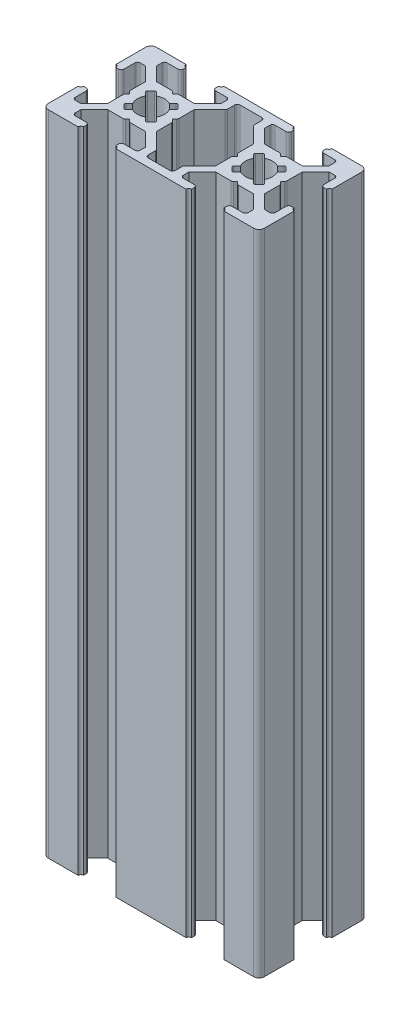
from build123d import *

# Parameters (mm, degrees)
BOSS_EXTRUDE1_DEPTH = 120
FILLET1_R           = 1
FILLET2_R           = 0.5
FILLET3_R           = 0.25
FILLET5_R           = 0.25
FILLET6_R           = 0.5
FILLET7_R           = 0.5
FILLET8_R           = 0.5


with BuildPart() as part:
    # Sketch2 → Boss-Extrude1 (new body)
    with BuildSketch(Plane(origin=(0, 0, 0), x_dir=(1, 0, 0), z_dir=(0, 1, 0))):
        with BuildLine():
            ThreePointArc((0, 13.5), (0.353553391, 13.353553391), (0.5, 13))
            Line((0.5, 13), (1.5, 13))
            Line((1.5, 13), (1.5, 16))
            Line((1.5, 16), (3, 16))
            Line((3, 16), (5.5, 13.5))
            Line((5.5, 13.5), (5.5, 10.5))
            Line((5.5, 10.5), (6, 10))
            Line((6, 10), (5.5, 9.5))
            Line((5.5, 9.5), (5.5, 6.5))
            Line((5.5, 6.5), (3, 4))
            Line((3, 4), (1.5, 4))
            Line((1.5, 4), (1.5, 7))
            Line((1.5, 7), (0.5, 7))
            ThreePointArc((0.5, 7), (0.353553391, 6.646446609), (0, 6.5))
            Line((0, 6.5), (0, 0))
            Line((0, 0), (6.5, 0))
            ThreePointArc((6.5, 0), (6.646446609, 0.353553391), (7, 0.5))
            Line((7, 0.5), (7, 1.5))
            Line((7, 1.5), (4, 1.5))
            Line((4, 1.5), (4, 3))
            Line((4, 3), (6.5, 5.5))
            Line((6.5, 5.5), (9.5, 5.5))
            Line((9.5, 5.5), (10, 6))
            Line((10, 6), (10.5, 5.5))
            Line((10.5, 5.5), (13.5, 5.5))
            Line((13.5, 5.5), (16, 3))
            Line((16, 3), (16, 1.5))
            Line((16, 1.5), (13, 1.5))
            Line((13, 1.5), (13, 0.5))
            ThreePointArc((13, 0.5), (13.353553391, 0.353553391), (13.5, 0))
            Line((13.5, 0), (26.5, 0))
            ThreePointArc((26.5, 0), (26.646446609, 0.353553391), (27, 0.5))
            Line((27, 0.5), (27, 1.5))
            Line((27, 1.5), (24, 1.5))
            Line((24, 1.5), (24, 3))
            Line((24, 3), (26.5, 5.5))
            Line((26.5, 5.5), (29.5, 5.5))
            Line((29.5, 5.5), (30, 6))
            Line((30, 6), (30.5, 5.5))
            Line((30.5, 5.5), (33.5, 5.5))
            Line((33.5, 5.5), (36, 3))
            Line((36, 3), (36, 1.5))
            Line((36, 1.5), (33, 1.5))
            Line((33, 1.5), (33, 0.5))
            ThreePointArc((33, 0.5), (33.353553391, 0.353553391), (33.5, 0))
            Line((33.5, 0), (40, 0))
            Line((40, 0), (40, 6.5))
            ThreePointArc((40, 6.5), (39.646446609, 6.646446609), (39.5, 7))
            Line((39.5, 7), (38.5, 7))
            Line((38.5, 7), (38.5, 4))
            Line((38.5, 4), (37, 4))
            Line((37, 4), (34.5, 6.5))
            Line((34.5, 6.5), (34.5, 9.5))
            Line((34.5, 9.5), (34, 10))
            Line((34, 10), (34.5, 10.5))
            Line((34.5, 10.5), (34.5, 13.5))
            Line((34.5, 13.5), (37, 16))
            Line((37, 16), (38.5, 16))
            Line((38.5, 16), (38.5, 13))
            Line((38.5, 13), (39.5, 13))
            ThreePointArc((39.5, 13), (39.646446609, 13.353553391), (40, 13.5))
            Line((40, 13.5), (40, 20))
            Line((40, 20), (33.5, 20))
            ThreePointArc((33.5, 20), (33.353553391, 19.646446609), (33, 19.5))
            Line((33, 19.5), (33, 18.5))
            Line((33, 18.5), (36, 18.5))
            Line((36, 18.5), (36, 17))
            Line((36, 17), (33.5, 14.5))
            Line((33.5, 14.5), (30.5, 14.5))
            Line((30.5, 14.5), (30, 14))
            Line((30, 14), (29.5, 14.5))
            Line((29.5, 14.5), (26.5, 14.5))
            Line((26.5, 14.5), (24, 17))
            Line((24, 17), (24, 18.5))
            Line((24, 18.5), (27, 18.5))
            Line((27, 18.5), (27, 19.5))
            ThreePointArc((27, 19.5), (26.646446609, 19.646446609), (26.5, 20))
            Line((26.5, 20), (13.5, 20))
            ThreePointArc((13.5, 20), (13.353553391, 19.646446609), (13, 19.5))
            Line((13, 19.5), (13, 18.5))
            Line((13, 18.5), (16, 18.5))
            Line((16, 18.5), (16, 17))
            Line((16, 17), (13.5, 14.5))
            Line((13.5, 14.5), (10.5, 14.5))
            Line((10.5, 14.5), (10, 14))
            Line((10, 14), (9.5, 14.5))
            Line((9.5, 14.5), (6.5, 14.5))
            Line((6.5, 14.5), (4, 17))
            Line((4, 17), (4, 18.5))
            Line((4, 18.5), (7, 18.5))
            Line((7, 18.5), (7, 19.5))
            ThreePointArc((7, 19.5), (6.646446609, 19.646446609), (6.5, 20))
            Line((6.5, 20), (0, 20))
            Line((0, 20), (0, 13.5))
        make_face()
        with BuildLine():
            Line((11.195582496, 12.195582496), (12, 13))
            Line((12, 13), (13, 12))
            Line((13, 12), (12.195582496, 11.195582496))
            ThreePointArc((12.195582496, 11.195582496), (12.422700584, 10.616864556), (12.5, 10))
            ThreePointArc((12.5, 10), (12.422700584, 9.383135444), (12.195582496, 8.804417504))
            Line((12.195582496, 8.804417504), (13, 8))
            Line((13, 8), (12, 7))
            Line((12, 7), (11.195582496, 7.804417504))
            ThreePointArc((11.195582496, 7.804417504), (10, 7.5), (8.804417504, 7.804417504))
            Line((8.804417504, 7.804417504), (8, 7))
            Line((8, 7), (7, 8))
            Line((7, 8), (7.804417504, 8.804417504))
            ThreePointArc((7.804417504, 8.804417504), (7.5, 10), (7.804417504, 11.195582496))
            Line((7.804417504, 11.195582496), (7, 12))
            Line((7, 12), (8, 13))
            Line((8, 13), (8.804417504, 12.195582496))
            ThreePointArc((8.804417504, 12.195582496), (10, 12.5), (11.195582496, 12.195582496))
        make_face(mode=Mode.SUBTRACT)
        Polygon((17.5, 16.5), (17.5, 18.5), (22.5, 18.5), (22.5, 16.5), (25.5, 13.5), (25.5, 10.5), (26, 10), (25.5, 9.5), (25.5, 6.5), (22.5, 3.5), (22.5, 1.5), (17.5, 1.5), (17.5, 3.5), (14.5, 6.5), (14.5, 9.5), (14, 10), (14.5, 10.5), (14.5, 13.5), align=None, mode=Mode.SUBTRACT)
        with BuildLine():
            Line((28.804417504, 7.804417504), (28, 7))
            Line((28, 7), (27, 8))
            Line((27, 8), (27.804417504, 8.804417504))
            ThreePointArc((27.804417504, 8.804417504), (27.5, 10), (27.804417504, 11.195582496))
            Line((27.804417504, 11.195582496), (27, 12))
            Line((27, 12), (28, 13))
            Line((28, 13), (28.804417504, 12.195582496))
            ThreePointArc((28.804417504, 12.195582496), (30, 12.5), (31.195582496, 12.195582496))
            Line((31.195582496, 12.195582496), (32, 13))
            Line((32, 13), (33, 12))
            Line((33, 12), (32.195582496, 11.195582496))
            ThreePointArc((32.195582496, 11.195582496), (32.422700584, 10.616864556), (32.5, 10))
            ThreePointArc((32.5, 10), (32.422700584, 9.383135444), (32.195582496, 8.804417504))
            Line((32.195582496, 8.804417504), (33, 8))
            Line((33, 8), (32, 7))
            Line((32, 7), (31.195582496, 7.804417504))
            ThreePointArc((31.195582496, 7.804417504), (30, 7.5), (28.804417504, 7.804417504))
        make_face(mode=Mode.SUBTRACT)
    extrude(amount=BOSS_EXTRUDE1_DEPTH)

    # Fillet1
    fillet1_edges = [part.edges().sort_by_distance(p)[0] for p in [
        (40, 60, 0),
        (0, 60, 0),
        (0, 60, -20),
        (40, 60, -20),
    ]]
    fillet(fillet1_edges, radius=FILLET1_R)

    # Fillet2
    fillet2_edges = [part.edges().sort_by_distance(p)[0] for p in [
        (7, 60, -18.5),
        (4, 60, -18.5),
        (9.5, 60, -14.5),
        (10.5, 60, -14.5),
        (16, 60, -18.5),
        (13, 60, -18.5),
    ]]
    fillet(fillet2_edges, radius=FILLET2_R)

    # Fillet3
    fillet3_edges = [part.edges().sort_by_distance(p)[0] for p in [
        (13, 60, -12),
        (12, 60, -13),
        (8, 60, -13),
        (7, 60, -12),
        (7, 60, -8),
        (8, 60, -7),
        (12, 60, -7),
        (13, 60, -8),
    ]]
    fillet(fillet3_edges, radius=FILLET3_R)

    # Fillet5
    fillet5_edges = [part.edges().sort_by_distance(p)[0] for p in [
        (27, 60, -8),
        (28, 60, -7),
        (32, 60, -7),
        (33, 60, -8),
        (33, 60, -12),
        (32, 60, -13),
        (28, 60, -13),
        (27, 60, -12),
    ]]
    fillet(fillet5_edges, radius=FILLET5_R)

    # Fillet6
    fillet6_edges = [part.edges().sort_by_distance(p)[0] for p in [
        (33, 60, -1.5),
        (36, 60, -1.5),
        (30.5, 60, -5.5),
        (29.5, 60, -5.5),
        (24, 60, -1.5),
        (27, 60, -1.5),
        (13, 60, -1.5),
        (16, 60, -1.5),
        (10.5, 60, -5.5),
        (9.5, 60, -5.5),
        (4, 60, -1.5),
        (7, 60, -1.5),
        (1.5, 60, -7),
        (1.5, 60, -4),
        (5.5, 60, -9.5),
        (5.5, 60, -10.5),
        (1.5, 60, -16),
        (1.5, 60, -13),
        (27, 60, -18.5),
        (24, 60, -18.5),
        (29.5, 60, -14.5),
        (30.5, 60, -14.5),
        (36, 60, -18.5),
        (33, 60, -18.5),
        (38.5, 60, -13),
        (38.5, 60, -16),
        (34.5, 60, -10.5),
        (34.5, 60, -9.5),
        (38.5, 60, -4),
        (38.5, 60, -7),
    ]]
    fillet(fillet6_edges, radius=FILLET6_R)

    # Fillet7
    fillet7_edges = [part.edges().sort_by_distance(p)[0] for p in [
        (22.5, 60, -16.5),
        (22.5, 60, -18.5),
        (17.5, 60, -18.5),
        (17.5, 60, -16.5),
        (17.5, 60, -3.5),
        (17.5, 60, -1.5),
        (22.5, 60, -1.5),
        (22.5, 60, -3.5),
    ]]
    fillet(fillet7_edges, radius=FILLET7_R)

    # Fillet8
    fillet8_edges = [part.edges().sort_by_distance(p)[0] for p in [
        (25.5, 60, -10.5),
        (14.5, 60, -10.5),
        (14.5, 60, -9.5),
        (25.5, 60, -9.5),
    ]]
    fillet(fillet8_edges, radius=FILLET8_R)


solid = part.part
